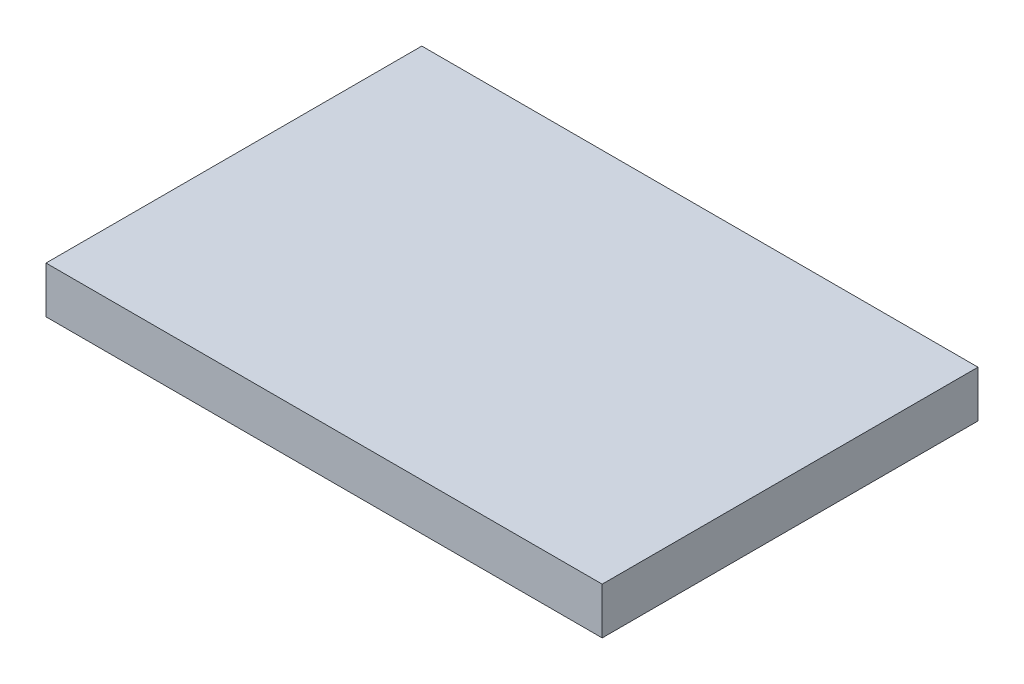
from build123d import *

# Parameters (mm, degrees)
SKETCH1_W           = 185
SKETCH1_H           = 125
BOSS_EXTRUDE1_DEPTH = 15.5


with BuildPart() as part:
    # Sketch1 → Boss-Extrude1 (new body)
    with BuildSketch(Plane(origin=(0, 0, 0), x_dir=(1, 0, 0), z_dir=(0, 1, 0))):
        Rectangle(SKETCH1_W, SKETCH1_H)
    extrude(amount=BOSS_EXTRUDE1_DEPTH)


solid = part.part
